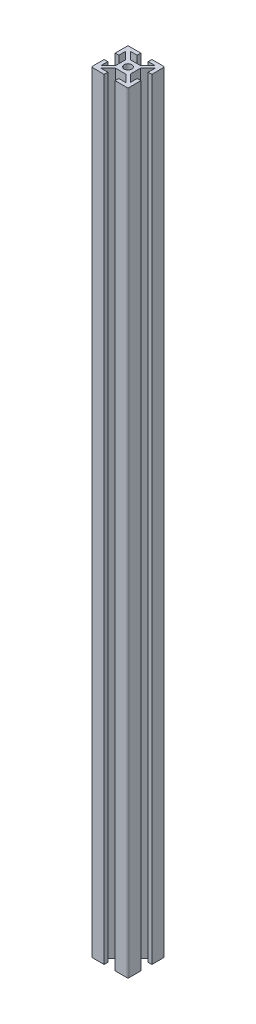
from build123d import *

# Parameters (mm, degrees)
SKETCH1_R           = 2.1
BOSS_EXTRUDE1_DEPTH = 420


with BuildPart() as part:
    # Sketch1 → Boss-Extrude1 (new body)
    with BuildSketch(Plane(origin=(0, 420, 0), x_dir=(1, 0, 0), z_dir=(0, 1, 0))):
        with BuildLine():
            Line((4, 2.746364236), (8, 6.746364236))
            Line((8, 6.746364236), (8, 3))
            Line((8, 3), (10, 3))
            Line((10, 3), (10, 9.5))
            ThreePointArc((10, 9.5), (9.853553391, 9.853553391), (9.5, 10))
            Line((9.5, 10), (3, 10))
            Line((3, 10), (3, 8))
            Line((3, 8), (6.863334179, 8))
            Line((6.863334179, 8), (2.863334179, 4))
            Line((2.863334179, 4), (-2.75, 4))
            Line((-2.75, 4), (-6.75, 8))
            Line((-6.75, 8), (-3, 8))
            Line((-3, 8), (-3, 10))
            Line((-3, 10), (-9.5, 10))
            ThreePointArc((-9.5, 10), (-9.853553391, 9.853553391), (-10, 9.5))
            Line((-10, 9.5), (-10, 3))
            Line((-10, 3), (-8, 3))
            Line((-8, 3), (-8, 6.75))
            Line((-8, 6.75), (-4, 2.75))
            Line((-4, 2.75), (-4, -2.75))
            Line((-4, -2.75), (-8, -6.75))
            Line((-8, -6.75), (-8, -3))
            Line((-8, -3), (-10, -3))
            Line((-10, -3), (-10, -9.5))
            ThreePointArc((-10, -9.5), (-9.853553391, -9.853553391), (-9.5, -10))
            Line((-9.5, -10), (-3, -10))
            Line((-3, -10), (-3, -8))
            Line((-3, -8), (-6.75, -8))
            Line((-6.75, -8), (-2.75, -4))
            Line((-2.75, -4), (2.868469119, -4))
            Line((2.868469119, -4), (6.868469119, -8))
            Line((6.868469119, -8), (3, -8))
            Line((3, -8), (3, -10))
            Line((3, -10), (9.5, -10))
            ThreePointArc((9.5, -10), (9.853553391, -9.853553391), (10, -9.5))
            Line((10, -9.5), (10, -3))
            Line((10, -3), (8, -3))
            Line((8, -3), (8, -6.665189266))
            Line((8, -6.665189266), (4, -2.665189266))
            Line((4, -2.665189266), (4, 2.746364236))
        make_face()
        Circle(SKETCH1_R, mode=Mode.SUBTRACT)
    extrude(amount=-BOSS_EXTRUDE1_DEPTH)


solid = part.part
